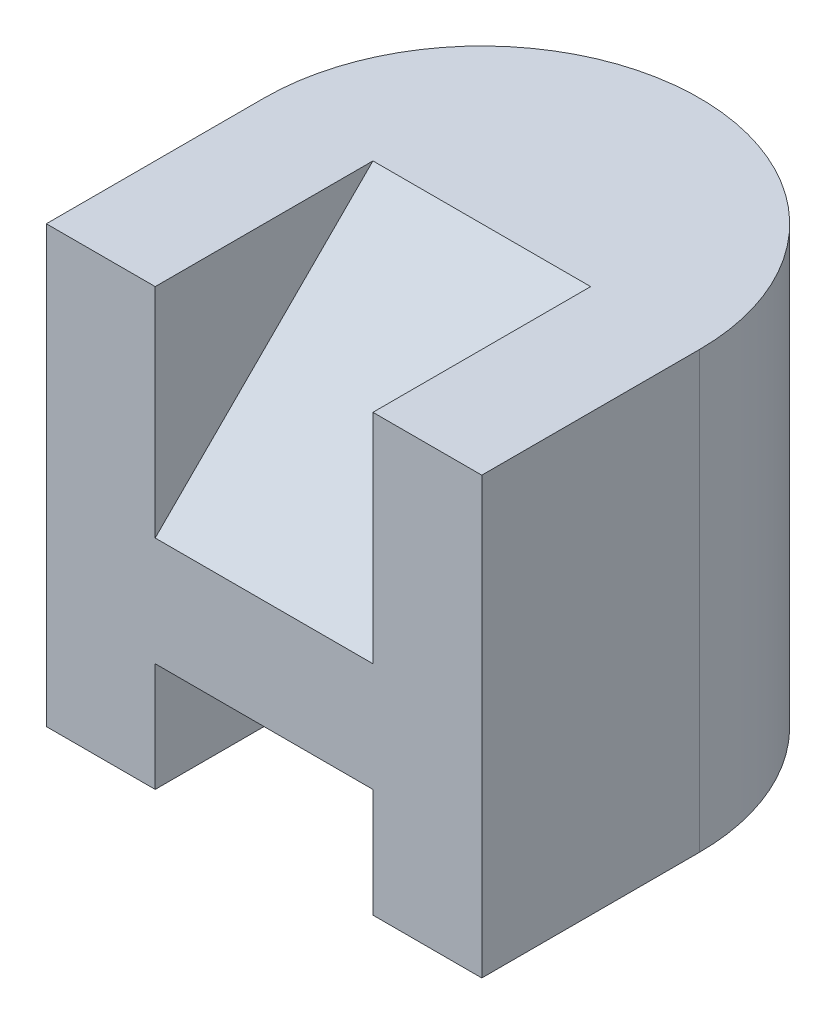
from build123d import *

# Parameters (mm, degrees)
BOSS_EXTRUDE1_DEPTH = 4
SKETCH2_W           = 2
SKETCH2_H           = 1
CUT_EXTRUDE1_DEPTH  = 4
CUT_EXTRUDE2_DEPTH  = 1


with BuildPart() as part:
    # Sketch1 → Boss-Extrude1 (new body)
    with BuildSketch(Plane(origin=(0, 0, 0), x_dir=(1, 0, 0), z_dir=(0, 1, 0))):
        with BuildLine():
            Line((-2, -2), (-2, 0))
            ThreePointArc((-2, 0), (0, 2), (2, 0))
            Line((2, 0), (2, -2))
            Line((2, -2), (-2, -2))
        make_face()
    extrude(amount=BOSS_EXTRUDE1_DEPTH)

    # Sketch2 → Cut-Extrude1 (cut)
    with BuildSketch(Plane.XY.offset(2)):
        with Locations((0, 0.5)):
            Rectangle(SKETCH2_W, SKETCH2_H)
    extrude(amount=-CUT_EXTRUDE1_DEPTH, mode=Mode.SUBTRACT)

    # Sketch3 → Cut-Extrude2 (cut, symmetric)
    with BuildSketch(Plane(origin=(0, 0, 0), x_dir=(0, 0, -1), z_dir=(1, 0, 0))):
        Polygon((0, 4), (-2, 2), (-2, 4), align=None)
    extrude(amount=CUT_EXTRUDE2_DEPTH, both=True, mode=Mode.SUBTRACT)


solid = part.part
